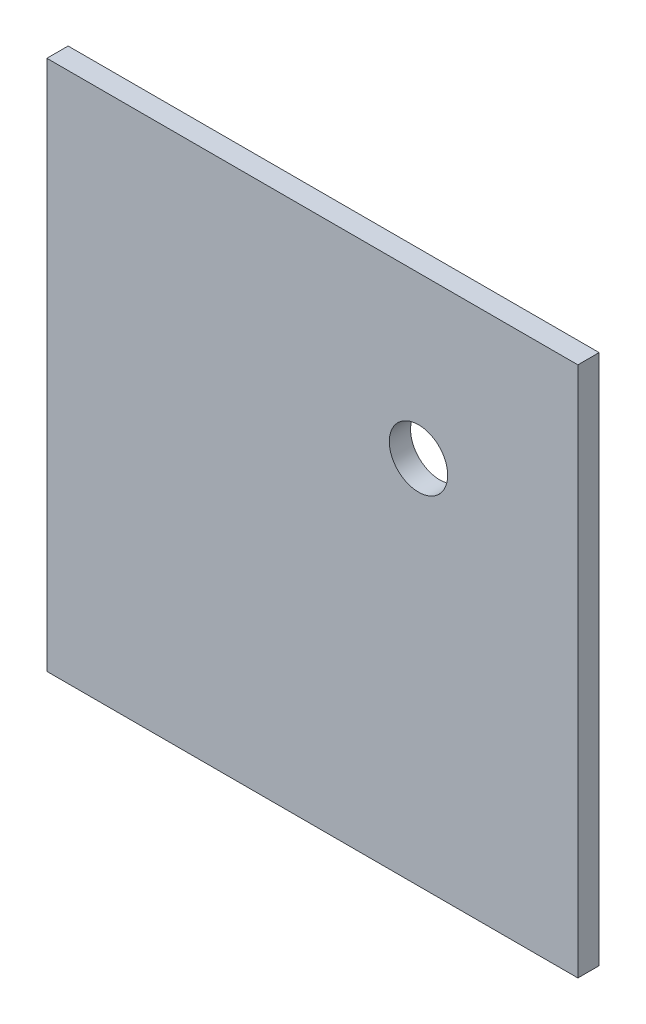
from build123d import *

# Parameters (mm, degrees)
SKETCH1_W           = 100
SKETCH1_H           = 100
BOSS_EXTRUDE1_DEPTH = 4
SKETCH2_R           = 4.75
CUT_EXTRUDE1_DEPTH  = 2
SKETCH3_R           = 5.5
CUT_EXTRUDE2_DEPTH  = 5


with BuildPart() as part:
    # Sketch1 → Boss-Extrude1 (new body)
    with BuildSketch(Plane.XY):
        Rectangle(SKETCH1_W, SKETCH1_H)
    extrude(amount=BOSS_EXTRUDE1_DEPTH)

    # Sketch2 → Cut-Extrude1 (cut)
    with BuildSketch(Plane(origin=(0, 0, 0), x_dir=(-1, 0, 0), z_dir=(0, 0, -1))):
        with Locations((45, 45)):
            Circle(SKETCH2_R)
        with Locations((45, -45)):
            Circle(SKETCH2_R)
        with Locations((-45, -45)):
            Circle(SKETCH2_R)
        with Locations((-45, 45)):
            Circle(SKETCH2_R)
    extrude(amount=-CUT_EXTRUDE1_DEPTH, mode=Mode.SUBTRACT)

    # Sketch3 → Cut-Extrude2 (cut, through all)
    with BuildSketch(Plane(origin=(-38.404344239, -79.614153906, 4), x_dir=(1, 0, 0), z_dir=(0, 0, 1))):
        with Locations((58.387586461, 99.345162416)):
            Circle(SKETCH3_R)
    extrude(amount=-CUT_EXTRUDE2_DEPTH, mode=Mode.SUBTRACT)


solid = part.part
